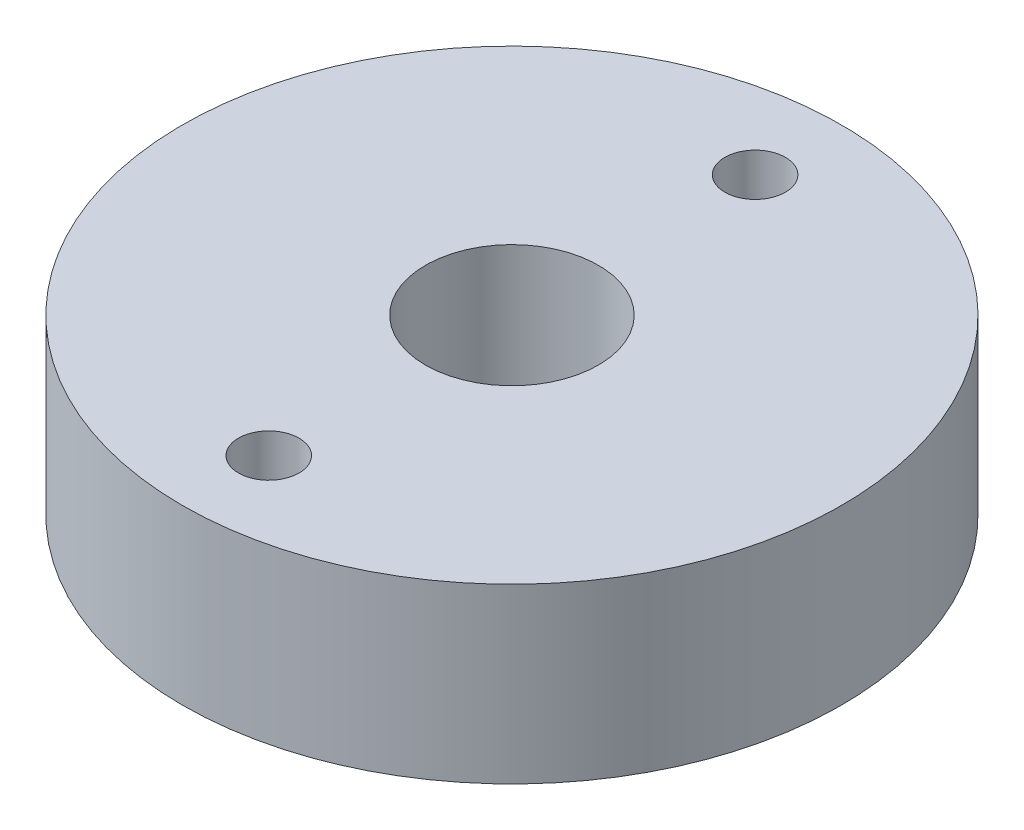
from build123d import *

# Parameters (mm, degrees)
SKETCH1_R           = 19.055
SKETCH1_R_2         = 5
SKETCH1_R_3         = 1.75
BOSS_EXTRUDE1_DEPTH = 10


with BuildPart() as part:
    # Sketch1 → Boss-Extrude1 (new body)
    with BuildSketch(Plane(origin=(0, 0, 0), x_dir=(1, 0, 0), z_dir=(0, 1, 0))):
        Circle(SKETCH1_R)
        Circle(SKETCH1_R_2, mode=Mode.SUBTRACT)
        with Locations((0, -14.06)):
            Circle(SKETCH1_R_3, mode=Mode.SUBTRACT)
        with Locations((0, 14.06)):
            Circle(SKETCH1_R_3, mode=Mode.SUBTRACT)
    extrude(amount=BOSS_EXTRUDE1_DEPTH)


solid = part.part
